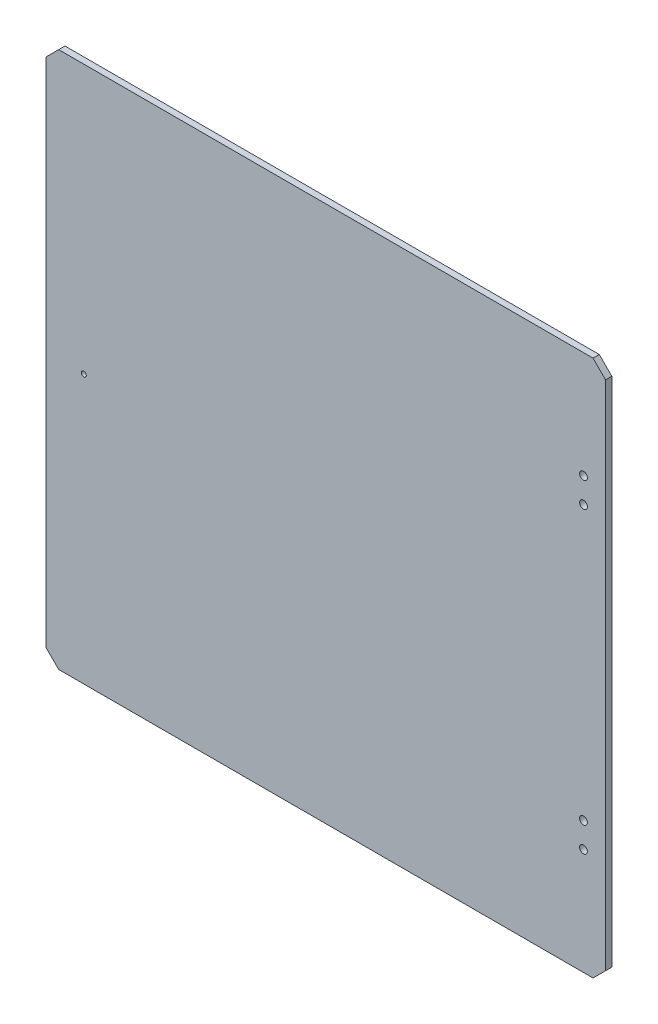
from build123d import *

# Parameters (mm, degrees)
SCHIZZO1_R                   = 3.1
SCHIZZO1_R_2                 = 2
ESTRUSIONE_ESTRUSIONE1_DEPTH = 5


with BuildPart() as part:
    # Schizzo1 → Estrusione-Estrusione1 (new body)
    with BuildSketch(Plane.XY):
        Polygon((-223, 204), (-213, 214), (213, 214), (223, 204), (223, -204), (213, -214), (-213, -214), (-223, -204), align=None)
        with Locations((205.4, 129)):
            Circle(SCHIZZO1_R, mode=Mode.SUBTRACT)
        with Locations((205.4, 109)):
            Circle(SCHIZZO1_R, mode=Mode.SUBTRACT)
        with Locations((205.4, -109)):
            Circle(SCHIZZO1_R, mode=Mode.SUBTRACT)
        with Locations((205.4, -129)):
            Circle(SCHIZZO1_R, mode=Mode.SUBTRACT)
        with Locations((-193, 0)):
            Circle(SCHIZZO1_R_2, mode=Mode.SUBTRACT)
    extrude(amount=ESTRUSIONE_ESTRUSIONE1_DEPTH)


solid = part.part
